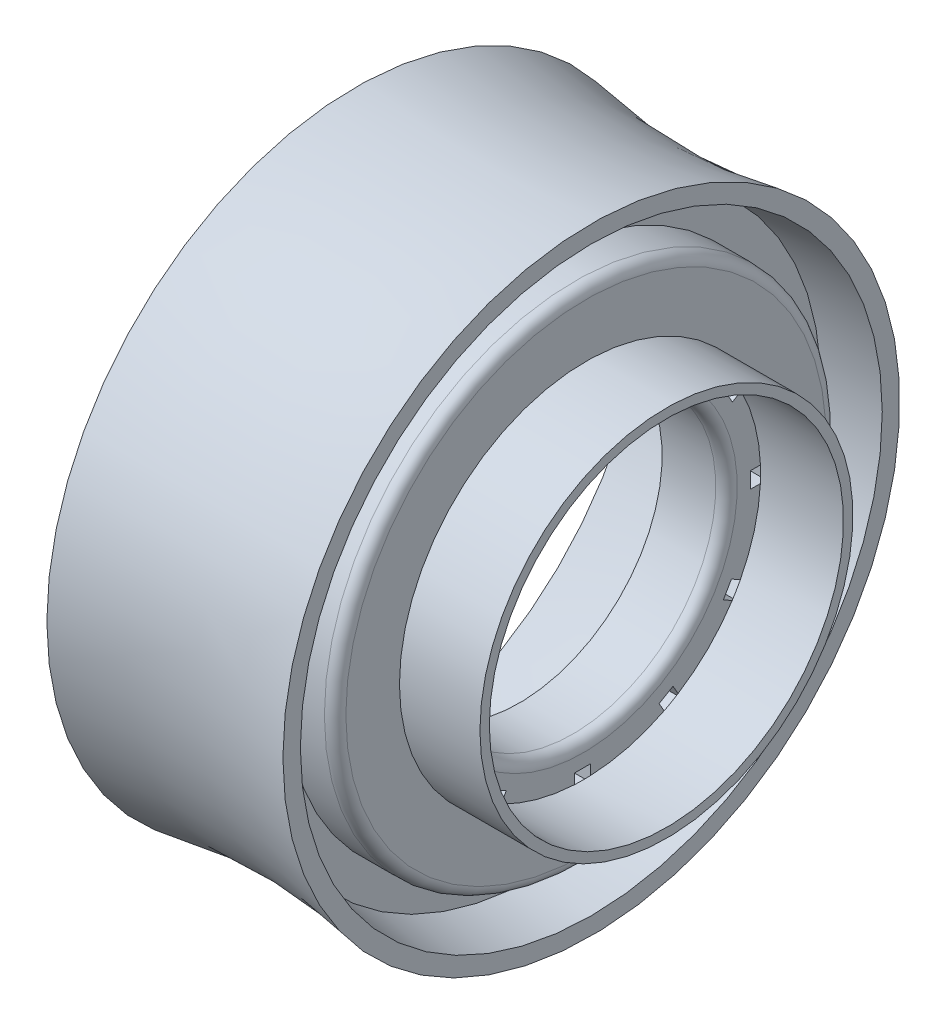
from build123d import *

# Parameters (mm, degrees)
SHELL1_T           = -0.8128
FILLET1_R          = 0.508
SKETCH3_W          = 0.762
SKETCH3_H          = 0.762
CUT_EXTRUDE1_DEPTH = 1.016


with BuildPart() as part:
    # Sketch1 → Revolve1 (revolve)
    with BuildSketch(Plane.XY, mode=Mode.PRIVATE) as revolve1_sk:
        with BuildLine():
            Line((0, 0), (0, 14.605))
            ThreePointArc((0, 14.605), (5.588, 14.065513703), (11.176, 14.605))
            Line((11.176, 14.605), (11.176, 0))
            Line((11.176, 0), (0, 0))
        make_face()
    revolve(revolve1_sk.sketch.rotate(Axis((-10.447687892, 0, 0), (1, 0, 0)), 90), axis=Axis((-10.447687892, 0, 0), (1, 0, 0)))

    # Shell1
    shell1_openings = [part.faces().sort_by_distance(p)[0] for p in [
        (0, 0, 0),
        (11.176, 0, 0),
    ]]
    offset(amount=SHELL1_T, openings=shell1_openings, kind=Kind.INTERSECTION)

    # Sketch2 → Revolve2 (revolve)
    with BuildSketch(Plane.XY, mode=Mode.PRIVATE) as revolve2_sk:
        with BuildLine():
            Line((8.636, 13.407835256), (8.636, 11.878888362))
            Line((8.636, 11.878888362), (10.922, 11.878888362))
            Line((10.922, 11.878888362), (10.922, 8.830888362))
            Line((10.922, 8.830888362), (14.732, 8.830888362))
            Line((14.732, 8.830888362), (14.732, 8.38570101))
            Line((14.732, 8.38570101), (10.805439867, 8.38570101))
            Line((10.805439867, 8.38570101), (10.805439867, 7.279783375))
            ThreePointArc((10.805439867, 7.279783375), (10.656650112, 6.92057313), (10.297439867, 6.771783375))
            Line((10.297439867, 6.771783375), (7.757439867, 6.771783375))
            Line((7.757439867, 6.771783375), (7.757439867, 7.279783375))
            Line((7.757439867, 7.279783375), (10.077783765, 7.279783375))
            ThreePointArc((10.077783765, 7.279783375), (10.233104084, 7.344119158), (10.297439867, 7.499439477))
            Line((10.297439867, 7.499439477), (10.297439867, 8.38570101))
            Line((10.297439867, 8.38570101), (6.741439867, 8.38570101))
            Line((6.741439867, 8.38570101), (6.741439867, 8.830888362))
            Line((6.741439867, 8.830888362), (10.297439867, 8.830888362))
            Line((10.297439867, 8.830888362), (10.297439867, 11.412306581))
            Line((10.297439867, 11.412306581), (8.128, 11.412306581))
            Line((8.128, 11.412306581), (8.128, 13.360351664))
            ThreePointArc((8.128, 13.360351664), (8.38210087, 13.383014307), (8.636, 13.407835256))
        make_face()
    revolve(revolve2_sk.sketch.rotate(Axis((-18.402780465, 0, 0), (1, 0, 0)), 90), axis=Axis((-18.402780465, 0, 0), (1, 0, 0)))

    # Fillet1
    fillet1_edges = [part.edges().sort_by_distance(p)[0] for p in [
        (10.922, 0, -11.878888362),
    ]]
    fillet(fillet1_edges, radius=FILLET1_R)

    # Sketch3 → Cut-Extrude1 (cut)
    with BuildSketch(Plane(origin=(10.805439867, 0, 0), x_dir=(0, 0, -1), z_dir=(1, 0, 0))):
        Polygon((4.038854556, 7.665935745), (3.657854556, 7.006024387), (4.317765913, 6.625024387), (4.698765913, 7.284935745), align=None)
        with Locations((0.045782775, 8.277322377)):
            Rectangle(SKETCH3_W, SKETCH3_H)
        Polygon((7.33071852, 4.619467821), (6.670807162, 4.238467821), (7.051807162, 3.578556464), (7.71171852, 3.959556464), align=None)
        with Locations((8.277322377, -0.045782775)):
            Rectangle(SKETCH3_W, SKETCH3_H)
        Polygon((7.665935745, -4.038854556), (7.006024387, -3.657854556), (6.625024387, -4.317765913), (7.284935745, -4.698765913), align=None)
        Polygon((4.619467821, -7.33071852), (4.238467821, -6.670807162), (3.578556464, -7.051807162), (3.959556464, -7.71171852), align=None)
        with Locations((-0.045782775, -8.277322377)):
            Rectangle(SKETCH3_W, SKETCH3_H)
        Polygon((-4.038854556, -7.665935745), (-3.657854556, -7.006024387), (-4.317765913, -6.625024387), (-4.698765913, -7.284935745), align=None)
        Polygon((-7.33071852, -4.619467821), (-6.670807162, -4.238467821), (-7.051807162, -3.578556464), (-7.71171852, -3.959556464), align=None)
        with Locations((-8.277322377, 0.045782775)):
            Rectangle(SKETCH3_W, SKETCH3_H)
        Polygon((-7.665935745, 4.038854556), (-7.006024387, 3.657854556), (-6.625024387, 4.317765913), (-7.284935745, 4.698765913), align=None)
        Polygon((-4.619467821, 7.33071852), (-4.238467821, 6.670807162), (-3.578556464, 7.051807162), (-3.959556464, 7.71171852), align=None)
    extrude(amount=-CUT_EXTRUDE1_DEPTH, mode=Mode.SUBTRACT)


solid = part.part
